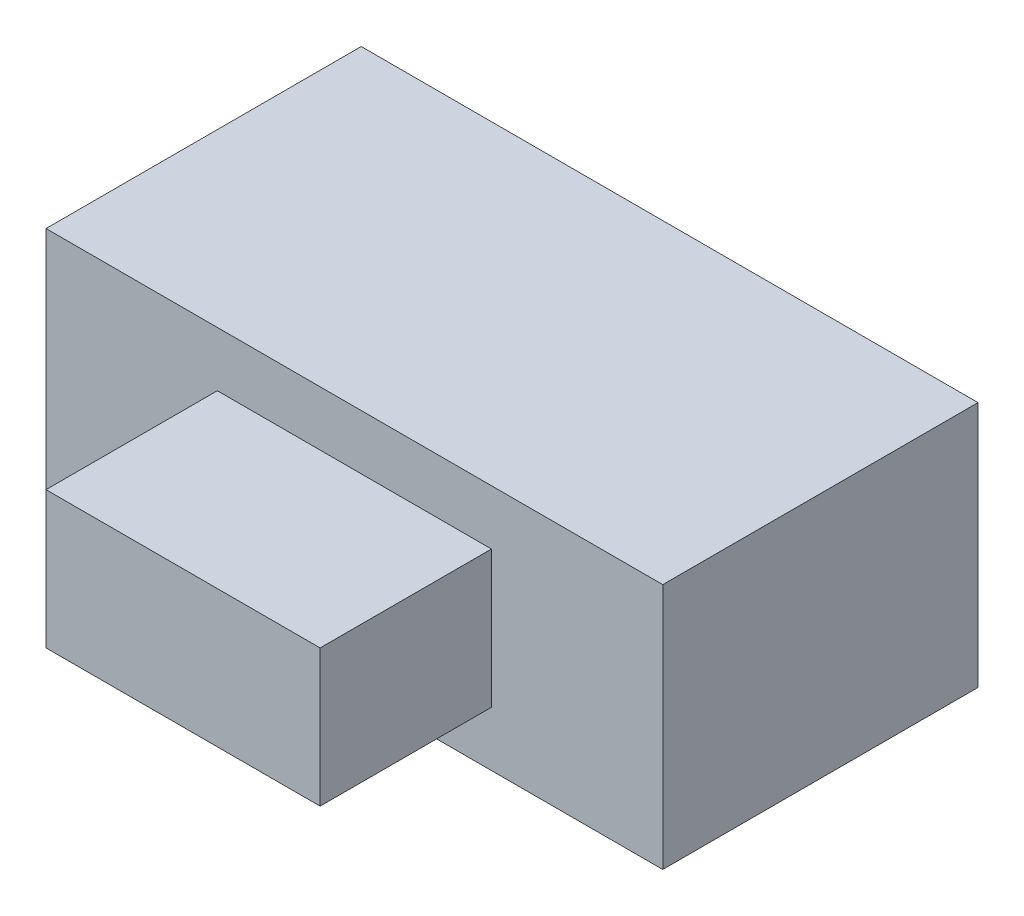
from build123d import *

# Parameters (mm, degrees)
SKETCH1_W           = 4.5
SKETCH1_H           = 2.3
BOSS_EXTRUDE1_DEPTH = 1.8
SKETCH2_W           = 2
SKETCH2_H           = 1
BOSS_EXTRUDE2_DEPTH = 1.25


with BuildPart() as part:
    # Sketch1 → Boss-Extrude1 (new body)
    with BuildSketch(Plane(origin=(0, 0, 0), x_dir=(1, 0, 0), z_dir=(0, 1, 0))):
        Rectangle(SKETCH1_W, SKETCH1_H)
    extrude(amount=BOSS_EXTRUDE1_DEPTH)

    # Sketch2 → Boss-Extrude2 (add)
    with BuildSketch(Plane.XY.offset(1.15)):
        with Locations((0, 0.9)):
            Rectangle(SKETCH2_W, SKETCH2_H)
    extrude(amount=BOSS_EXTRUDE2_DEPTH)


solid = part.part
